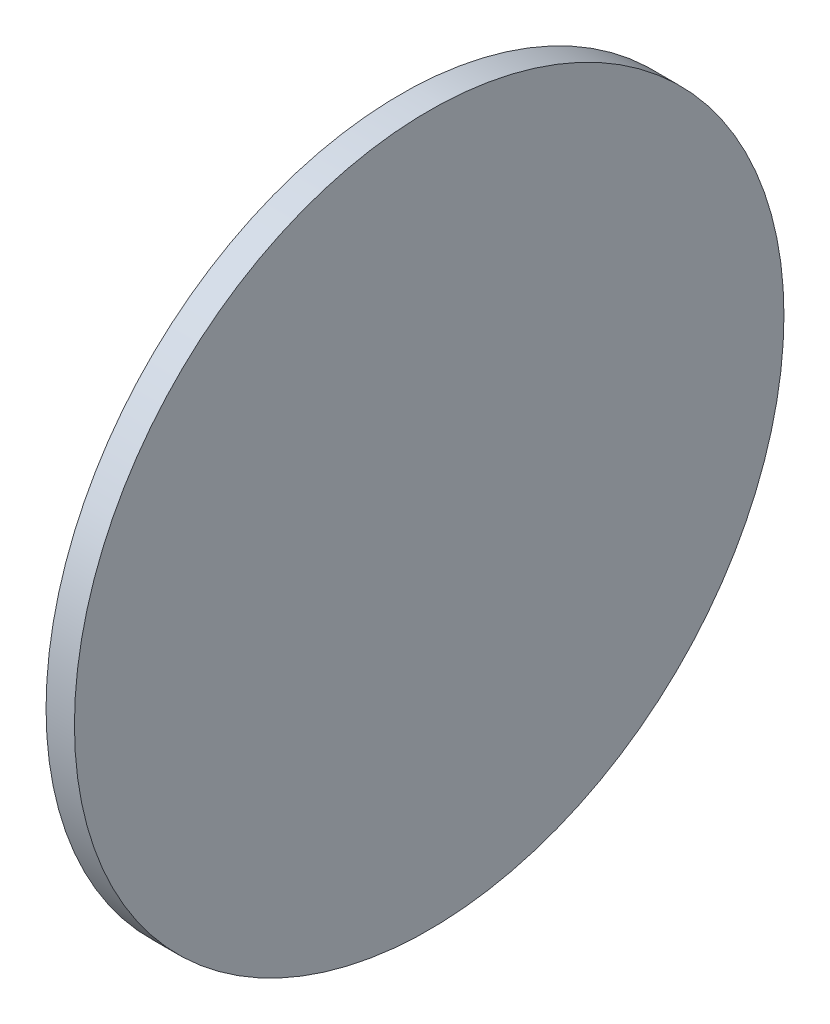
from build123d import *

# Parameters (mm, degrees)
SKETCH_1_W = 2
SKETCH_1_H = 25


with BuildPart() as part:
    # 草图1 → 旋转2 (revolve)
    with BuildSketch(Plane.XY, mode=Mode.PRIVATE) as revolve_2_sk:
        with Locations((1, 12.5)):
            Rectangle(SKETCH_1_W, SKETCH_1_H)
    revolve(revolve_2_sk.sketch.rotate(Axis((0, 0, 0), (1, 0, 0)), 90), axis=Axis((0, 0, 0), (1, 0, 0)))  # turned: the seam where the file's is


solid = part.part
